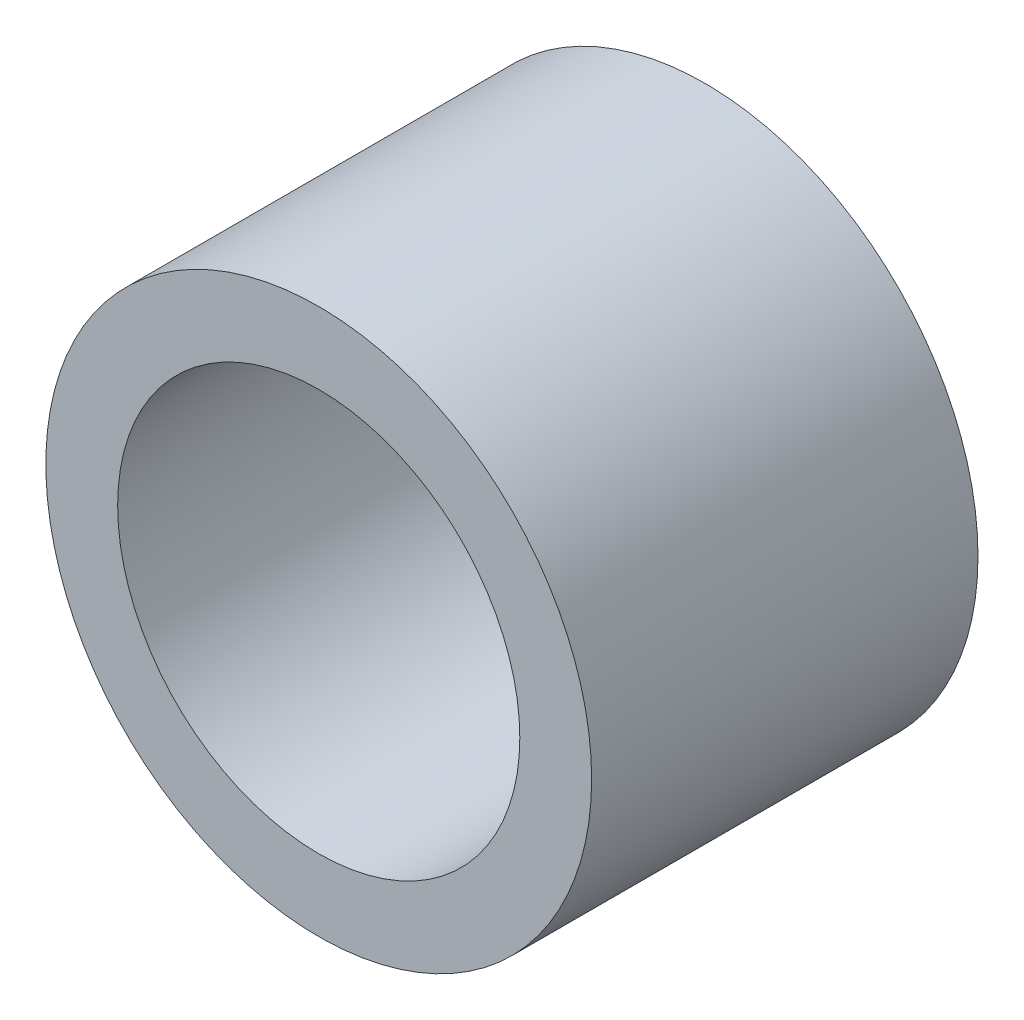
from build123d import *

# Parameters (mm, degrees)
SKETCH1_R           = 4.826
SKETCH1_R_2         = 3.556
BOSS_EXTRUDE1_DEPTH = 6.8326


with BuildPart() as part:
    # Sketch1 → Boss-Extrude1 (new body)
    with BuildSketch(Plane.XY):
        Circle(SKETCH1_R)
        Circle(SKETCH1_R_2, mode=Mode.SUBTRACT)
    extrude(amount=BOSS_EXTRUDE1_DEPTH)


solid = part.part
